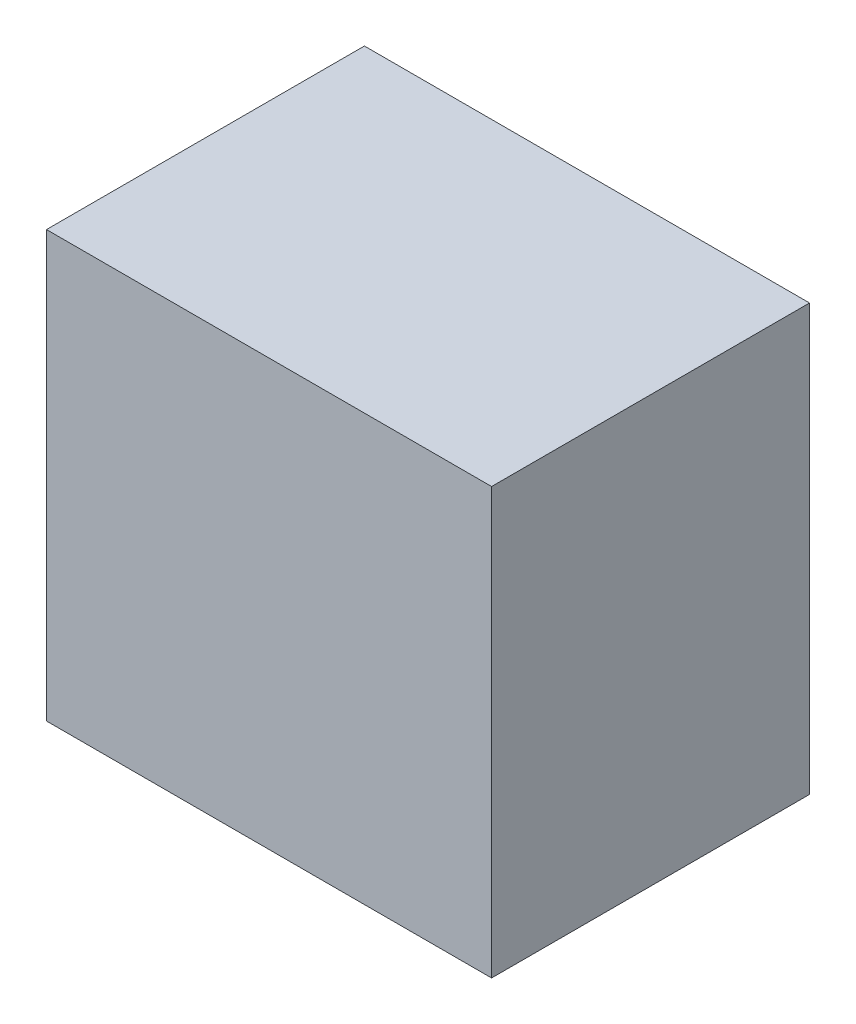
from build123d import *

# Parameters (mm, degrees)
SKETCH1_W           = 177.8
SKETCH1_H           = 170.033057851
BOSS_EXTRUDE1_DEPTH = 127


with BuildPart() as part:
    # Sketch1 → Boss-Extrude1 (new body)
    with BuildSketch(Plane.XY):
        with Locations((20.152066116, -10.233471074)):
            Rectangle(SKETCH1_W, SKETCH1_H)
    extrude(amount=BOSS_EXTRUDE1_DEPTH)


solid = part.part
